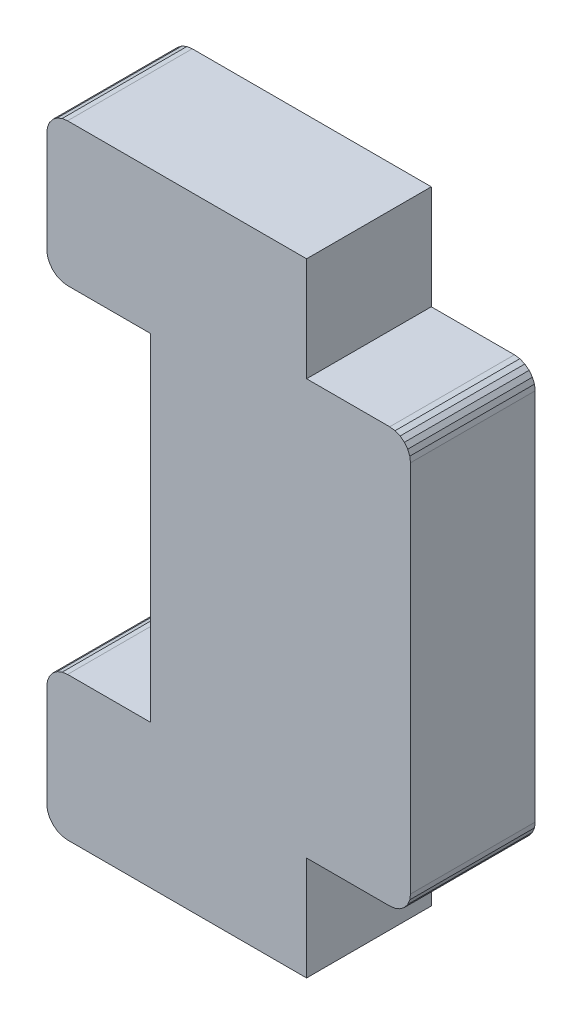
from build123d import *

# Parameters (mm, degrees)
RESSALTO_EXTRUS_O1_DEPTH = 6


with BuildPart() as part:
    # Model → Ressalto-extrusão1 (new body)
    with BuildSketch(Plane.XY):
        Polygon((28.385212082, 9.048001095), (28.351137909, 9.30682014), (28.351137909, 14.20682014), (28.385212082, 14.465639185), (28.485112505, 14.70682014), (28.644031127, 14.913926921), (28.851137909, 15.072845544), (29.092318864, 15.172745966), (29.351137909, 15.20682014), (33.351137909, 15.20682014), (33.351137909, 31.406815144), (29.351137909, 31.406815144), (29.092318864, 31.440889318), (28.851137909, 31.54078974), (28.644031127, 31.699708363), (28.485112505, 31.906815144), (28.385212082, 32.147996099), (28.351137909, 32.406815144), (28.351137909, 37.275279302), (28.385212082, 37.534098347), (28.485112505, 37.775279302), (28.644031127, 37.982386083), (28.851137909, 38.141304706), (29.092318864, 38.241205128), (29.351137909, 38.275279302), (40.851137909, 38.275279302), (40.851137909, 33.275279302), (44.851137909, 33.275279302), (45.109956954, 33.241205128), (45.351137909, 33.141304706), (45.55824469, 32.982386083), (45.717163312, 32.775279302), (45.817063735, 32.534098347), (45.851137909, 32.275279302), (45.851137909, 14.30682014), (45.817063735, 14.048001095), (45.717163312, 13.80682014), (45.55824469, 13.599713359), (45.351137909, 13.440794736), (45.109956954, 13.340894314), (44.851137909, 13.30682014), (40.851137909, 13.30682014), (40.851137909, 8.30682014), (29.351137909, 8.30682014), (29.092318864, 8.340894314), (28.851137909, 8.440794736), (28.644031127, 8.599713359), (28.485112505, 8.80682014), align=None)
    extrude(amount=RESSALTO_EXTRUS_O1_DEPTH)


solid = part.part
